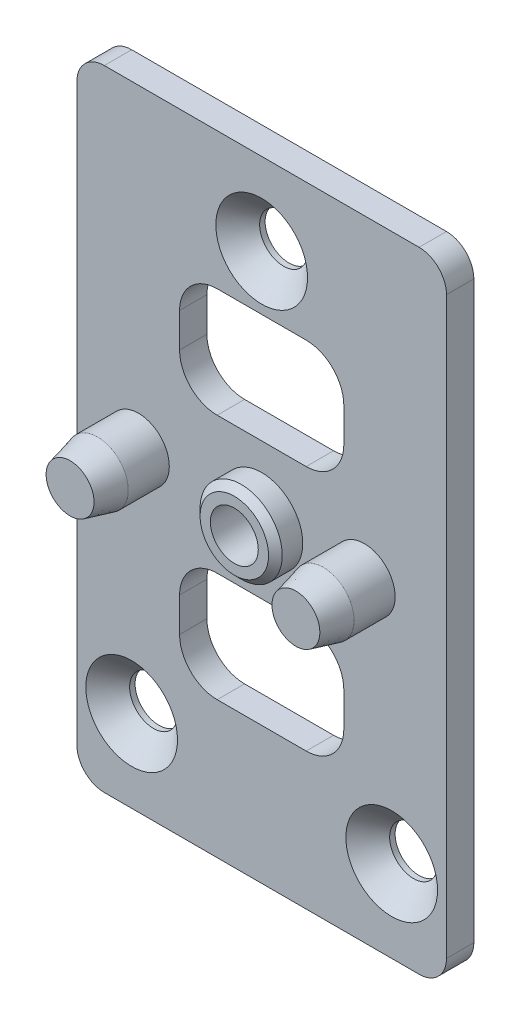
from build123d import *

# Parameters (mm, degrees)
SKETCH1_W                                    = 27
SKETCH1_H                                    = 46
SKETCH1_R                                    = 1.75
BOSS_EXTRUDE1_DEPTH                          = 1
SKETCH2_R                                    = 3
SKETCH2_R_2                                  = 1.75
SKETCH2_R_3                                  = 2.25
BOSS_EXTRUDE2_DEPTH                          = 5
SKETCH3_R                                    = 3.5
CUT_EXTRUDE1_DEPTH                           = 3
CHAMFER1_SIZE                                = 2
CHAMFER1_SIZE2                               = 0.5
CHAMFER1_PART_2_SIZE                         = 2
CHAMFER1_PART_2_SIZE2                        = 0.5
CHAMFER2_SIZE                                = 0.5
CSK_FOR_M3_FLAT_COUNTERSUNK_HEAD_SCR_2_COUNT = 2
CSK_FOR_M3_FLAT_COUNTERSUNK_HEAD_SCR_2_PITCH = 35.302266216
CSK_FOR_M3_FLAT_COUNTERSUNK_HEAD_SCR_3_COUNT = 2
CSK_FOR_M3_FLAT_COUNTERSUNK_HEAD_SCR_3_PITCH = 35.302266216
FILLET1_R                                    = 2


with BuildPart() as part:
    # Sketch1 → Boss-Extrude1 (new body, symmetric)
    with BuildSketch(Plane.XY):
        Rectangle(SKETCH1_W, SKETCH1_H)
        Circle(SKETCH1_R, mode=Mode.SUBTRACT)
        with Locations((0, 17)):
            Circle(SKETCH1_R, mode=Mode.SUBTRACT)
        with Locations((-9.5, -17)):
            Circle(SKETCH1_R, mode=Mode.SUBTRACT)
        with Locations((9.5, -17)):
            Circle(SKETCH1_R, mode=Mode.SUBTRACT)
        with BuildLine():
            Line((-3.25, 13), (3.25, 13))
            ThreePointArc((3.25, 13), (5.194543648, 12.194543648), (6, 10.25))
            Line((6, 10.25), (6, 7.75))
            ThreePointArc((6, 7.75), (5.194543648, 5.805456352), (3.25, 5))
            Line((3.25, 5), (-3.25, 5))
            ThreePointArc((-3.25, 5), (-5.194543648, 5.805456352), (-6, 7.75))
            Line((-6, 7.75), (-6, 10.25))
            ThreePointArc((-6, 10.25), (-5.194543648, 12.194543648), (-3.25, 13))
        make_face(mode=Mode.SUBTRACT)
        with BuildLine():
            Line((-3.25, -5), (3.25, -5))
            ThreePointArc((3.25, -5), (5.194543648, -5.805456352), (6, -7.75))
            Line((6, -7.75), (6, -10.25))
            ThreePointArc((6, -10.25), (5.194543648, -12.194543648), (3.25, -13))
            Line((3.25, -13), (-3.25, -13))
            ThreePointArc((-3.25, -13), (-5.194543648, -12.194543648), (-6, -10.25))
            Line((-6, -10.25), (-6, -7.75))
            ThreePointArc((-6, -7.75), (-5.194543648, -5.805456352), (-3.25, -5))
        make_face(mode=Mode.SUBTRACT)
    extrude(amount=BOSS_EXTRUDE1_DEPTH, both=True)

    # Sketch2 → Boss-Extrude2 (add)
    with BuildSketch(Plane.XY.offset(1)):
        Circle(SKETCH2_R)
        Circle(SKETCH2_R_2, mode=Mode.SUBTRACT)
        with Locations((-9, 0)):
            Circle(SKETCH2_R_3)
        with Locations((7.5, 0)):
            Circle(SKETCH2_R_3)
    extrude(amount=BOSS_EXTRUDE2_DEPTH)

    # Sketch3 → Cut-Extrude1 (cut)
    with BuildSketch(Plane.XY.offset(6)):
        Circle(SKETCH3_R)
    extrude(amount=-CUT_EXTRUDE1_DEPTH, mode=Mode.SUBTRACT)

    # Chamfer1
    chamfer1_edges = [part.edges().sort_by_distance(p)[0] for p in [
        (-11.25, 0, 6),
    ]]
    chamfer1_side = [part.faces().sort_by_distance(p)[0] for p in [
        (-11.25, 0, 3.5),
    ]]
    chamfer(chamfer1_edges, length=CHAMFER1_SIZE, length2=CHAMFER1_SIZE2, reference=chamfer1_side[0])

    # Chamfer1 part 2
    chamfer1_part_2_edges = [part.edges().sort_by_distance(p)[0] for p in [
        (5.25, 0, 6),
    ]]
    chamfer1_part_2_side = [part.faces().sort_by_distance(p)[0] for p in [
        (5.25, 0, 3.5),
    ]]
    chamfer(chamfer1_part_2_edges, length=CHAMFER1_PART_2_SIZE, length2=CHAMFER1_PART_2_SIZE2, reference=chamfer1_part_2_side[0])

    # Chamfer2
    chamfer2_edges = [part.edges().sort_by_distance(p)[0] for p in [
        (-3, 0, 3),
    ]]
    chamfer(chamfer2_edges, length=CHAMFER2_SIZE)

    # Sketch5 → CSK for M3 Flat Countersunk Head Screw1 (revolve, cut)
    with BuildSketch(Plane(origin=(0, 17, 1), x_dir=(0, -1, 0), z_dir=(1, 0, 0))):
        Polygon((0, 0), (0, 2), (1.7, 2), (1.7, 1.65), (3.35, 0), align=None)
    csk_for_m3_flat_countersunk_head_screw1 = revolve(axis=Axis((0, 17, 7.35), (0, 0, -1)), mode=Mode.SUBTRACT)

    # CSK for M3 Flat Countersunk Head Scr 2: CSK for M3 Flat Countersunk Head Screw1 ×2
    with Locations(*[Vector(-0.269104537, -0.963110974, 0) * (i * CSK_FOR_M3_FLAT_COUNTERSUNK_HEAD_SCR_2_PITCH) for i in range(1, CSK_FOR_M3_FLAT_COUNTERSUNK_HEAD_SCR_2_COUNT)]):
        add(csk_for_m3_flat_countersunk_head_screw1, mode=Mode.SUBTRACT)

    # CSK for M3 Flat Countersunk Head Scr 3: CSK for M3 Flat Countersunk Head Screw1 ×2
    with Locations(*[Vector(0.269104537, -0.963110974, 0) * (i * CSK_FOR_M3_FLAT_COUNTERSUNK_HEAD_SCR_3_PITCH) for i in range(1, CSK_FOR_M3_FLAT_COUNTERSUNK_HEAD_SCR_3_COUNT)]):
        add(csk_for_m3_flat_countersunk_head_screw1, mode=Mode.SUBTRACT)

    # Fillet1
    fillet1_edges = [part.edges().sort_by_distance(p)[0] for p in [
        (-13.5, 23, 0),
        (13.5, 23, 0),
        (13.5, -23, 0),
        (-13.5, -23, 0),
    ]]
    fillet(fillet1_edges, radius=FILLET1_R)


solid = part.part
